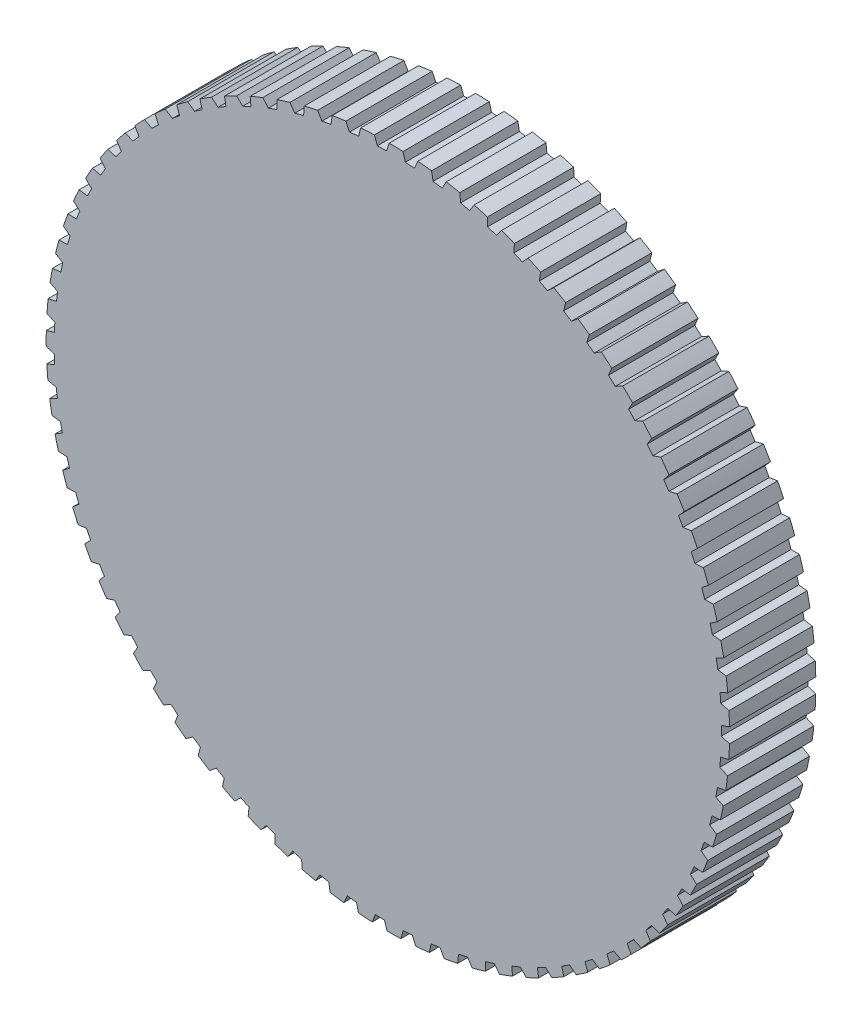
from build123d import *

# Parameters (mm, degrees)
AUFSATZ_LINEAR_AUSTRAGEN1_DEPTH = 3.75
KREISMUSTER1_COUNT              = 75


with BuildPart() as part:
    # Skizze1 → Aufsatz-Linear austragen1 (new body, symmetric)
    with BuildSketch(Plane.XY):
        with BuildLine():
            ThreePointArc((1.513001029, 28.960504621), (1.912299677, 28.936881483), (2.311234517, 28.907753199))
            Line((2.311234517, 28.907753199), (0, 0))
            Line((0, 0), (-0.115809751, 28.999768759))
            Line((-0.115809751, 28.999768759), (0.115809751, 29.69977421))
            ThreePointArc((0.115809751, 29.69977421), (0.715740747, 29.691374424), (1.315379644, 29.670857359))
            Line((1.315379644, 29.670857359), (1.513001029, 28.960504621))
        make_face()
    aufsatz_linear_austragen1 = extrude(amount=AUFSATZ_LINEAR_AUSTRAGEN1_DEPTH, both=True)

    # Kreismuster1: Aufsatz-Linear austragen1 ×75 about axis
    kreismuster1_axis = Axis((0, 0, 0), (0, 0, 1))
    for i in range(1, KREISMUSTER1_COUNT):
        add(aufsatz_linear_austragen1.rotate(kreismuster1_axis, i * 360 / KREISMUSTER1_COUNT))


solid = part.part
